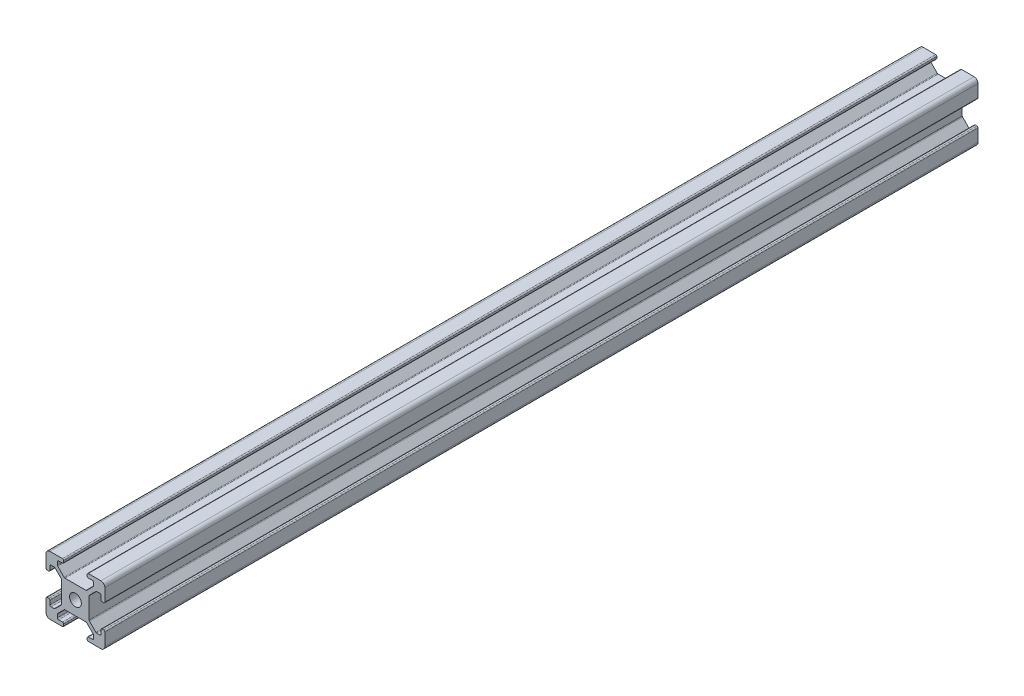
from build123d import *

# Parameters (mm, degrees)
SKETCH1_R           = 1.5
BOSS_EXTRUDE1_DEPTH = 222.5


with BuildPart() as part:
    # Sketch1 → Boss-Extrude1 (new body)
    with BuildSketch(Plane.XY):
        with BuildLine():
            Line((0.997149379, -0.010991612), (4.197149379, -0.010991612))
            ThreePointArc((4.197149379, -0.010991612), (4.409281413, 0.076876353), (4.497149379, 0.289008388))
            Line((4.497149379, 0.289008388), (4.497149379, 0.689008388))
            ThreePointArc((4.497149379, 0.689008388), (4.409281413, 0.901140422), (4.197149379, 0.989008388))
            Line((4.197149379, 0.989008388), (3.197149379, 0.989008388))
            ThreePointArc((3.197149379, 0.989008388), (2.985017344, 1.076876353), (2.897149379, 1.289008388))
            Line((2.897149379, 1.289008388), (2.897149379, 2.057637538))
            ThreePointArc((2.897149379, 2.057637538), (2.920422177, 2.174637797), (2.9866975, 2.273825827))
            Line((2.9866975, 2.273825827), (4.61806835, 3.905196677))
            ThreePointArc((4.61806835, 3.905196677), (4.71725638, 3.971472), (4.834256639, 3.994744798))
            Line((4.834256639, 3.994744798), (10.171514939, 3.994744798))
            ThreePointArc((10.171514939, 3.994744798), (10.288515198, 3.971472), (10.387703228, 3.905196677))
            Line((10.387703228, 3.905196677), (12.019074078, 2.273825827))
            ThreePointArc((12.019074078, 2.273825827), (12.085349401, 2.174637797), (12.1086222, 2.057637538))
            Line((12.1086222, 2.057637538), (12.1086222, 1.289008388))
            ThreePointArc((12.1086222, 1.289008388), (12.020754234, 1.076876353), (11.8086222, 0.989008388))
            Line((11.8086222, 0.989008388), (10.797149379, 0.989008388))
            ThreePointArc((10.797149379, 0.989008388), (10.585017344, 0.901140422), (10.497149379, 0.689008388))
            Line((10.497149379, 0.689008388), (10.497149379, 0.289008388))
            ThreePointArc((10.497149379, 0.289008388), (10.585017344, 0.076876353), (10.797149379, -0.010991612))
            Line((10.797149379, -0.010991612), (13.997149379, -0.010991612))
            ThreePointArc((13.997149379, -0.010991612), (14.70425616, 0.281901607), (14.997149379, 0.989008388))
            Line((14.997149379, 0.989008388), (14.997149379, 4.189008388))
            ThreePointArc((14.997149379, 4.189008388), (14.909281413, 4.401140422), (14.697149379, 4.489008388))
            Line((14.697149379, 4.489008388), (14.305261888, 4.489008388))
            ThreePointArc((14.305261888, 4.489008388), (14.093129854, 4.401140422), (14.005261888, 4.189008388))
            Line((14.005261888, 4.189008388), (14.005261888, 3.189008388))
            ThreePointArc((14.005261888, 3.189008388), (13.917393922, 2.976876353), (13.705261888, 2.889008388))
            Line((13.705261888, 2.889008388), (12.936632738, 2.889008388))
            ThreePointArc((12.936632738, 2.889008388), (12.819632479, 2.912281186), (12.720444449, 2.978556509))
            Line((12.720444449, 2.978556509), (11.089073599, 4.609927359))
            ThreePointArc((11.089073599, 4.609927359), (11.006246661, 4.70520219), (10.969948855, 4.826115648))
            Line((10.969948855, 4.826115648), (10.969948855, 10.163373948))
            ThreePointArc((10.969948855, 10.163373948), (11.00546556, 10.284783861), (11.087867966, 10.380761184))
            Line((11.087867966, 10.380761184), (12.719238816, 12.012132034))
            ThreePointArc((12.719238816, 12.012132034), (12.81656582, 12.07716386), (12.93137085, 12.1))
            Line((12.93137085, 12.1), (13.7, 12.1))
            ThreePointArc((13.7, 12.1), (13.912132034, 12.012132034), (14, 11.8))
            Line((14, 11.8), (14, 10.8))
            ThreePointArc((14, 10.8), (14.087867966, 10.587867966), (14.3, 10.5))
            Line((14.3, 10.5), (14.697149379, 10.5))
            ThreePointArc((14.697149379, 10.5), (14.909281413, 10.587867966), (14.997149379, 10.8))
            Line((14.997149379, 10.8), (14.997149379, 13.989008388))
            ThreePointArc((14.997149379, 13.989008388), (14.70425616, 14.696115169), (13.997149379, 14.989008388))
            Line((13.997149379, 14.989008388), (10.797149379, 14.989008388))
            ThreePointArc((10.797149379, 14.989008388), (10.585017344, 14.901140422), (10.497149379, 14.689008388))
            Line((10.497149379, 14.689008388), (10.497149379, 14.289008388))
            ThreePointArc((10.497149379, 14.289008388), (10.585017344, 14.076876353), (10.797149379, 13.989008388))
            Line((10.797149379, 13.989008388), (11.798829534, 13.989008388))
            ThreePointArc((11.798829534, 13.989008388), (12.010961569, 13.901140422), (12.098829534, 13.689008388))
            Line((12.098829534, 13.689008388), (12.098829534, 12.916322983))
            ThreePointArc((12.098829534, 12.916322983), (12.075993394, 12.801517953), (12.010961569, 12.704190949))
            Line((12.010961569, 12.704190949), (10.379590719, 11.072820099))
            ThreePointArc((10.379590719, 11.072820099), (10.282263714, 11.007788273), (10.167458684, 10.984952133))
            Line((10.167458684, 10.984952133), (4.830200384, 10.984952133))
            ThreePointArc((4.830200384, 10.984952133), (4.715395355, 11.007788273), (4.61806835, 11.072820099))
            Line((4.61806835, 11.072820099), (2.9866975, 12.704190949))
            ThreePointArc((2.9866975, 12.704190949), (2.920422177, 12.803378979), (2.897149379, 12.920379238))
            Line((2.897149379, 12.920379238), (2.897149379, 13.689008388))
            ThreePointArc((2.897149379, 13.689008388), (2.985017344, 13.901140422), (3.197149379, 13.989008388))
            Line((3.197149379, 13.989008388), (4.197149379, 13.989008388))
            ThreePointArc((4.197149379, 13.989008388), (4.409281413, 14.076876353), (4.497149379, 14.289008388))
            Line((4.497149379, 14.289008388), (4.497149379, 14.689008388))
            ThreePointArc((4.497149379, 14.689008388), (4.409281413, 14.901140422), (4.197149379, 14.989008388))
            Line((4.197149379, 14.989008388), (0.997149379, 14.989008388))
            ThreePointArc((0.997149379, 14.989008388), (0.290042597, 14.696115169), (-0.002850621, 13.989008388))
            Line((-0.002850621, 13.989008388), (-0.002850621, 10.789008388))
            ThreePointArc((-0.002850621, 10.789008388), (0.085017344, 10.576876353), (0.297149379, 10.489008388))
            Line((0.297149379, 10.489008388), (0.697149379, 10.489008388))
            ThreePointArc((0.697149379, 10.489008388), (0.909281413, 10.576876353), (0.997149379, 10.789008388))
            Line((0.997149379, 10.789008388), (0.997149379, 11.790199043))
            ThreePointArc((0.997149379, 11.790199043), (1.085017344, 12.002331078), (1.297149379, 12.090199043))
            Line((1.297149379, 12.090199043), (2.057928823, 12.090199043))
            ThreePointArc((2.057928823, 12.090199043), (2.174143192, 12.067250491), (2.272911478, 12.001849869))
            Line((2.272911478, 12.001849869), (3.912132034, 10.380761184))
            ThreePointArc((3.912132034, 10.380761184), (3.97928656, 10.281159192), (4.002885789, 10.163373948))
            Line((4.002885789, 10.163373948), (4.002885789, 4.826115648))
            ThreePointArc((4.002885789, 4.826115648), (3.979612991, 4.709115389), (3.913337668, 4.609927359))
            Line((3.913337668, 4.609927359), (2.281966818, 2.978556509))
            ThreePointArc((2.281966818, 2.978556509), (2.182778788, 2.912281186), (2.065778529, 2.889008388))
            Line((2.065778529, 2.889008388), (1.297149379, 2.889008388))
            ThreePointArc((1.297149379, 2.889008388), (1.085017344, 2.976876353), (0.997149379, 3.189008388))
            Line((0.997149379, 3.189008388), (0.997149379, 4.189008388))
            ThreePointArc((0.997149379, 4.189008388), (0.909281413, 4.401140422), (0.697149379, 4.489008388))
            Line((0.697149379, 4.489008388), (0.297149379, 4.489008388))
            ThreePointArc((0.297149379, 4.489008388), (0.085017344, 4.401140422), (-0.002850621, 4.189008388))
            Line((-0.002850621, 4.189008388), (-0.002850621, 0.989008388))
            ThreePointArc((-0.002850621, 0.989008388), (0.290042597, 0.281901607), (0.997149379, -0.010991612))
        make_face()
        with Locations((7.5, 7.5)):
            Circle(SKETCH1_R, mode=Mode.SUBTRACT)
    extrude(amount=BOSS_EXTRUDE1_DEPTH)


solid = part.part
